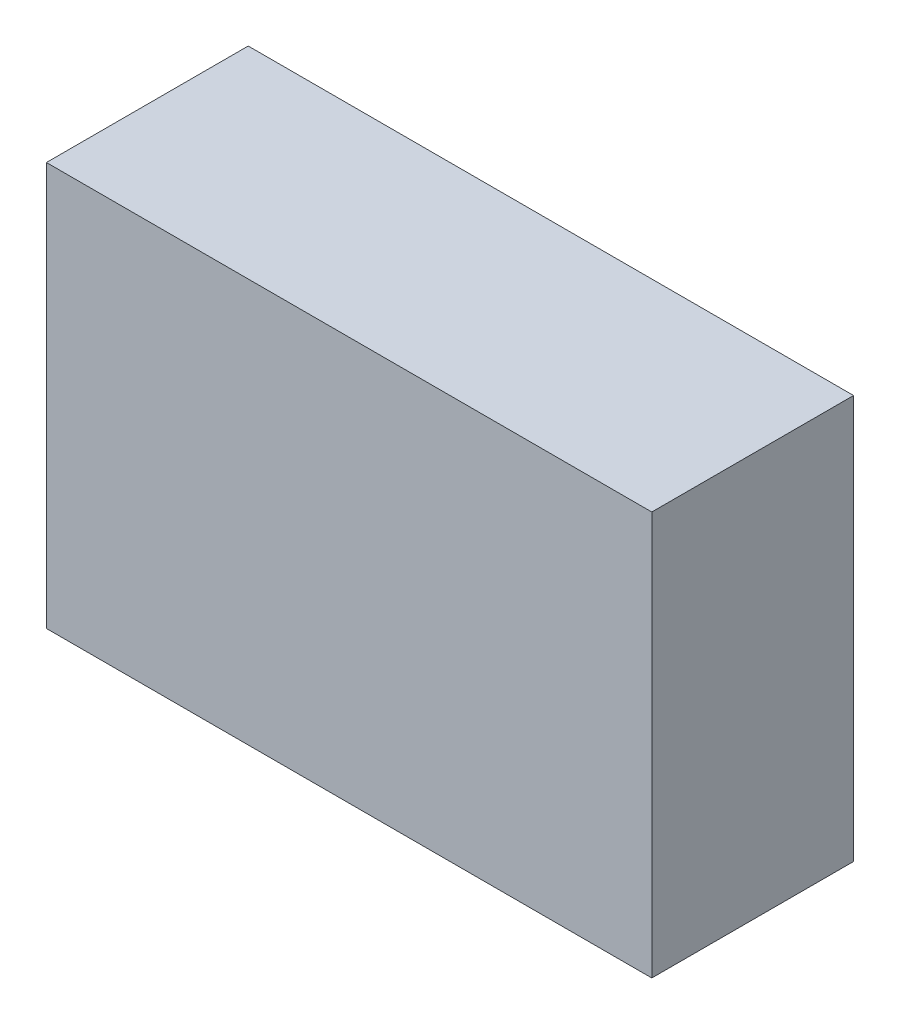
from build123d import *

# Parameters (mm, degrees)
SKIZZE1_W                       = 3
SKIZZE1_H                       = 1
AUFSATZ_LINEAR_AUSTRAGEN1_DEPTH = 2


with BuildPart() as part:
    # Skizze1 → Aufsatz-Linear austragen1 (new body)
    with BuildSketch(Plane(origin=(0, 0, 0), x_dir=(1, 0, 0), z_dir=(0, 1, 0))):
        with Locations((1.5, -0.5)):
            Rectangle(SKIZZE1_W, SKIZZE1_H)
    extrude(amount=AUFSATZ_LINEAR_AUSTRAGEN1_DEPTH)


solid = part.part
